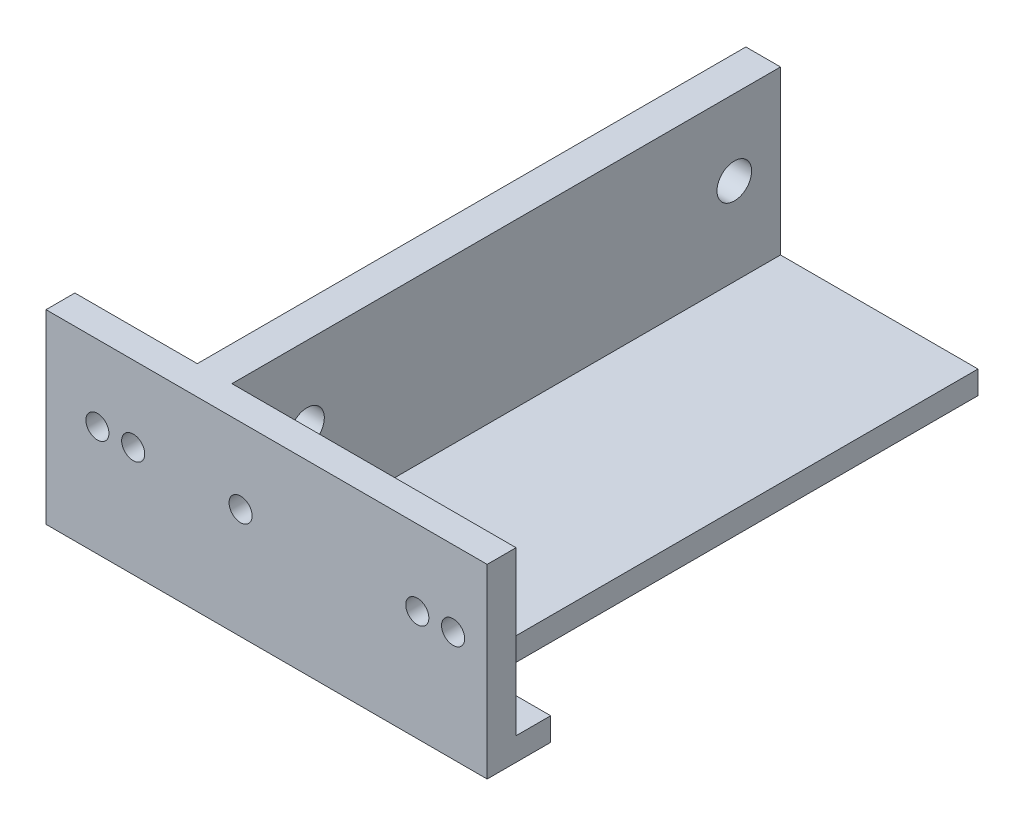
from build123d import *

# Parameters (mm, degrees)
SKETCH1_W                = 50
SKETCH1_H                = 16.1
BOSS_EXTRUDE1_DEPTH      = 3
SKETCH3_R                = 1.5
CUT_EXTRUDE1_DEPTH       = 4
SKETCH4_W                = 2.5
SKETCH4_H                = 16.1
BOSS_EXTRUDE2_DEPTH      = 35.4
BOSS_EXTRUDE2_DEPTH_BACK = 13.6
SKETCH6_R                = 1
CUT_EXTRUDE2_DEPTH       = 45
SKETCH10_W               = 49
SKETCH10_H               = 2
BOSS_EXTRUDE4_DEPTH      = 47.5
CUT_EXTRUDE5_DEPTH       = 15.1
CUT_EXTRUDE5_DEPTH_BACK  = 3


with BuildPart() as part:
    # Sketch1 → Boss-Extrude1 (new body)
    with BuildSketch(Plane(origin=(0, 0, 0), x_dir=(0, 0, -1), z_dir=(1, 0, 0))):
        with Locations((25, 8.05)):
            Rectangle(SKETCH1_W, SKETCH1_H)
    extrude(amount=BOSS_EXTRUDE1_DEPTH)

    # Sketch3 → Cut-Extrude1 (cut, through all)
    with BuildSketch(Plane(origin=(3, 0, 0), x_dir=(0, 0, -1), z_dir=(1, 0, 0))):
        with Locations((46, 9.55)):
            Circle(SKETCH3_R)
        with Locations((9, 9.55)):
            Circle(SKETCH3_R)
    extrude(amount=-CUT_EXTRUDE1_DEPTH, mode=Mode.SUBTRACT)

    # Sketch4 → Boss-Extrude2 (add, two sides)
    with BuildSketch(Plane(origin=(3, 0, 0), x_dir=(0, 0, -1), z_dir=(1, 0, 0))) as boss_extrude2_sk:
        with Locations((1.25, 8.05)):
            Rectangle(SKETCH4_W, SKETCH4_H)
    extrude(amount=BOSS_EXTRUDE2_DEPTH)
    extrude(boss_extrude2_sk.sketch, amount=-BOSS_EXTRUDE2_DEPTH_BACK)

    # Sketch6 → Cut-Extrude2 (cut)
    with BuildSketch(Plane(origin=(0, 0, -2.5), x_dir=(-1, 0, 0), z_dir=(0, 0, -1))):
        with Locations((6.15, 9.55)):
            Circle(SKETCH6_R)
        with Locations((3.05, 9.55)):
            Circle(SKETCH6_R)
        with Locations((-6.25, 9.55)):
            Circle(SKETCH6_R)
        with Locations((-21.55, 9.55)):
            Circle(SKETCH6_R)
        with Locations((-24.65, 9.55)):
            Circle(SKETCH6_R)
    extrude(amount=-CUT_EXTRUDE2_DEPTH, mode=Mode.SUBTRACT)

    # Sketch10 → Boss-Extrude4 (add)
    with BuildSketch(Plane(origin=(0, 0, -2.5), x_dir=(-1, 0, 0), z_dir=(0, 0, -1))):
        with Locations((-13.9, 1)):
            Rectangle(SKETCH10_W, SKETCH10_H)
    extrude(amount=BOSS_EXTRUDE4_DEPTH)

    # Sketch13 → Cut-Extrude5 (cut, two sides)
    with BuildSketch(Plane(origin=(0, 2, 0), x_dir=(1, 0, 0), z_dir=(0, 1, 0))) as cut_extrude5_sk:
        Polygon((20.1, 5.5), (20.1, 50), (38.4, 50), (38.4, 0), (27.6, 0), (27.6, 5.5), align=None)
    extrude(amount=CUT_EXTRUDE5_DEPTH, mode=Mode.SUBTRACT)
    extrude(cut_extrude5_sk.sketch, amount=-CUT_EXTRUDE5_DEPTH_BACK, mode=Mode.SUBTRACT)


solid = part.part
